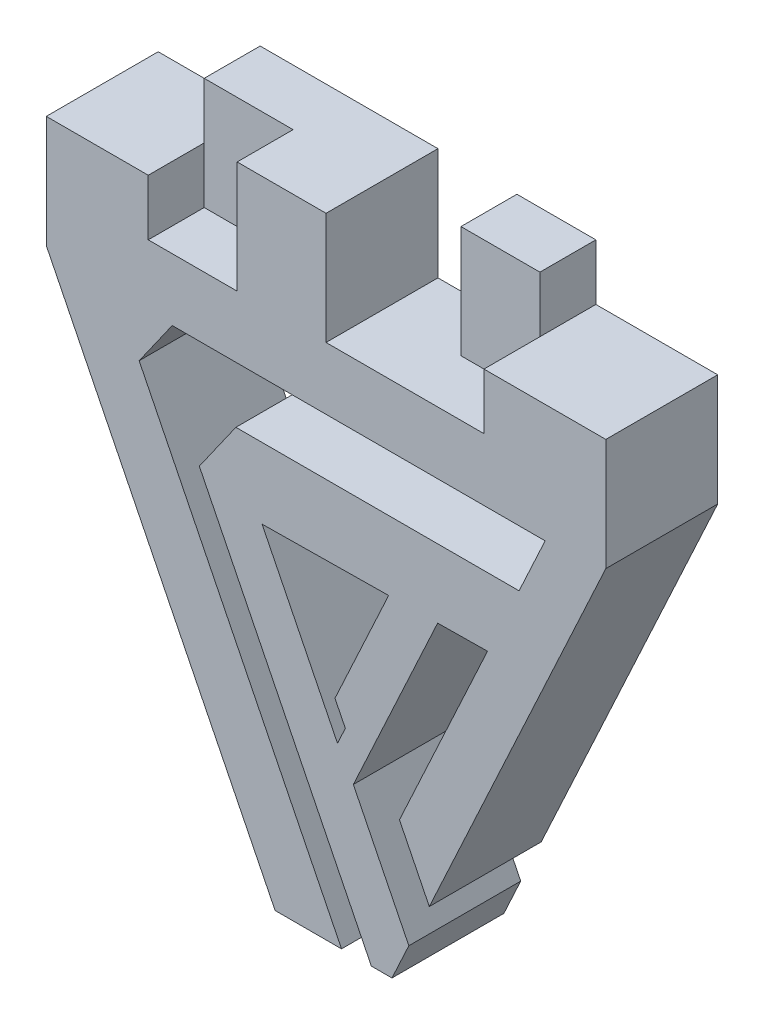
from build123d import *

# Parameters (mm, degrees)
EXTRUDE_1_DEPTH     = 40
EXTRUDE_5_DEPTH     = 20
CUT_EXTRUDE_1_DEPTH = 20
SHELL_1_T           = -4


with BuildPart() as part:
    # 草图2 → 凸台-拉伸1 (new body)
    with BuildSketch(Plane.XY):
        Polygon((-492.83766907737134, 3.399363384602765), (-492.83766907737134, -36.600636615400134), (-411.04350764937084, -201.54780387004163), (-387.3021178796635, -201.54780387004163), (-459.64889501148184, -55.65235437147672), (-447.824430393232, -38.845349288689015), (-314.51618126146934, -38.84534928868898), (-323.84350707219164, -58.973746582631264), (-425.06859632409555, -58.973746582631264), (-438.13417767710234, -77.54484466606092), (-376.6434698856671, -201.54780387004163), (-369.27276463278196, -201.54780387004163), (-363.24825517120325, -188.54689424122049), (-383.08030790431167, -148.55331936912614), (-352.9457720883425, -83.52289998835491), (-335.1213284507255, -83.31131920781937), (-366.59780107826595, -151.23764228433387), (-355.9291354649939, -172.7522117911716), (-292.83766907737163, -36.600636615400134), (-292.83766907737163, 3.399363384602765), align=None)
        Polygon((-388.745435454288, -138.64702410749163), (-415.7109887551389, -84.26793942985627), (-370.4625020076991, -83.73082812704564), (-389.6473299690999, -125.13174485915943), (-385.9436191741513, -132.60069610569766), align=None, mode=Mode.SUBTRACT)
    extrude(amount=EXTRUDE_1_DEPTH)

    # 草图3 → 凸台-拉伸5 (add)
    with BuildSketch(Plane(origin=(0, 3.399363384602765, 0), x_dir=(1, 0, 0), z_dir=(0, 1, 0))):
        Polygon((-336.3917831998655, -20.00000000000003), (-336.3917831998655, -5.981e-14), (-364.61472613861844, -3.469e-14), (-364.61472613861844, -20.000000000000018), align=None)
        Polygon((-392.8376690773715, -3.469e-14), (-456.3917831998654, -3.469e-14), (-456.3917831998654, -20.00000000000002), (-424.61472613861844, -20.00000000000001), (-424.61472613861844, -40), (-392.8376690773715, -39.999999999999986), align=None)
    extrude(amount=EXTRUDE_5_DEPTH)

    # 草图3<6> → 切除-拉伸1 (cut)
    with BuildSketch(Plane(origin=(0, 3.399363384602765, 0), x_dir=(1, 0, 0), z_dir=(0, 1, 0))):
        Polygon((-364.61472613861844, -20.000000000000018), (-364.61472613861844, -6.04e-14), (-392.8376690773715, -3.469e-14), (-392.8376690773715, -39.99999999999998), (-336.3917831998655, -39.99999999999998), (-336.3917831998655, -20.00000000000003), align=None)
        Polygon((-424.61472613861844, -20.00000000000001), (-456.39178319986536, -20.000000000000014), (-456.3917831998654, -40.00000000000006), (-424.61472613861844, -39.99999999999999), align=None)
    extrude(amount=-CUT_EXTRUDE_1_DEPTH, mode=Mode.SUBTRACT)

    # 抽壳1
    shell_1_openings = [part.faces().sort_by_distance(p)[0] for p in [
        (-393.958302549, -65.824912477, 0),
    ]]
    offset(amount=SHELL_1_T, openings=shell_1_openings, kind=Kind.INTERSECTION)


solid = part.part
